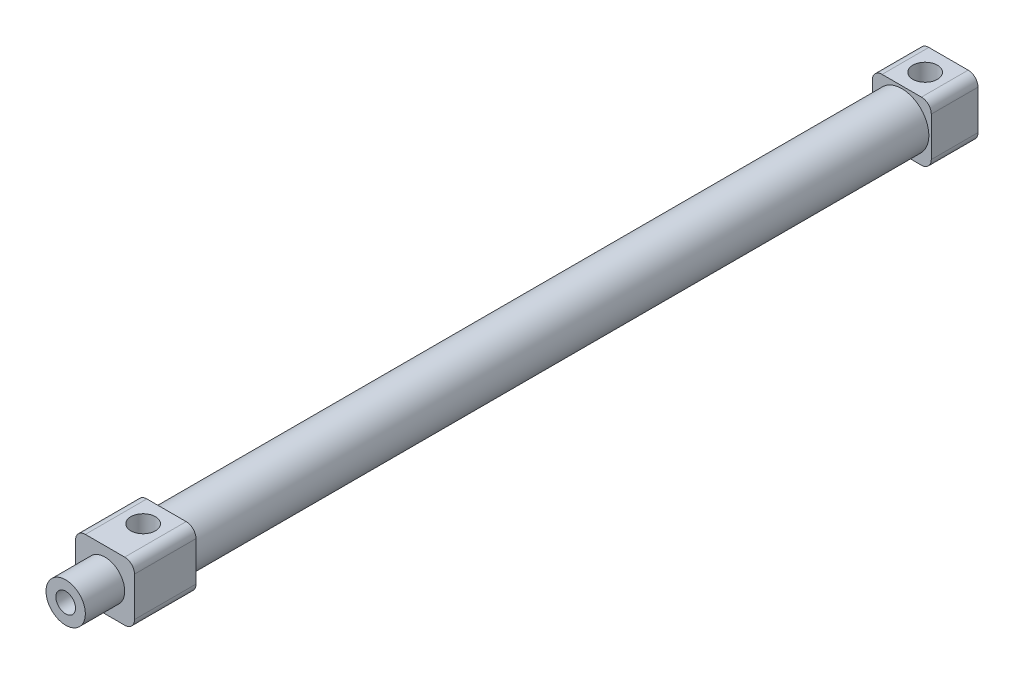
from build123d import *

# Parameters (mm, degrees)
SKETCH_1_W          = 12
SKETCH_1_H          = 12
EXTRUDE_1_DEPTH     = 9.5
SKETCH_2_R          = 5.5
EXTRUDE_2_DEPTH     = 149.5
SKETCH_3_W          = 12
SKETCH_3_H          = 12
EXTRUDE_3_DEPTH     = 12.5
SKETCH_4_R          = 4
EXTRUDE_4_DEPTH     = 8
SKETCH_5_R          = 2
CUT_EXTRUDE_1_DEPTH = 178.5
CUT_EXTRUDE_START   = -6
SKETCH_6_R          = 2.5
CUT_EXTRUDE_2_DEPTH = 6
FILLET_1_R          = 2


with BuildPart() as part:
    # 草图1 → 凸台-拉伸1 (new body)
    with BuildSketch(Plane.XY):
        Rectangle(SKETCH_1_W, SKETCH_1_H)
    extrude(amount=EXTRUDE_1_DEPTH)

    # 草图2 → 凸台-拉伸2 (add)
    with BuildSketch(Plane.XY.offset(9.5)):
        Circle(SKETCH_2_R)
    extrude(amount=EXTRUDE_2_DEPTH)

    # 草图3 → 凸台-拉伸3 (add)
    with BuildSketch(Plane.XY.offset(159)):
        Rectangle(SKETCH_3_W, SKETCH_3_H)
    extrude(amount=EXTRUDE_3_DEPTH)

    # 草图4 → 凸台-拉伸4 (add)
    with BuildSketch(Plane.XY.offset(171.5)):
        Circle(SKETCH_4_R)
    extrude(amount=EXTRUDE_4_DEPTH)

    # 草图5 → 切除-拉伸1 (cut)
    with BuildSketch(Plane.XY.offset(179.5)):
        Circle(SKETCH_5_R)
    extrude(amount=-CUT_EXTRUDE_1_DEPTH, mode=Mode.SUBTRACT)

    # 草图6 → 切除-拉伸2 (cut)
    with BuildSketch(Plane(origin=(0, 6, 0), x_dir=(1, 0, 0), z_dir=(0, 1, 0)).offset(CUT_EXTRUDE_START)):
        with Locations((0, -4.75)):
            Circle(SKETCH_6_R)
        with Locations((0, -163.75)):
            Circle(SKETCH_6_R)
    extrude(amount=CUT_EXTRUDE_2_DEPTH, mode=Mode.SUBTRACT)

    # 圆角1
    fillet_1_edges = [part.edges().sort_by_distance(p)[0] for p in [
        (6, -6, 165.25),
        (6, 6, 165.25),
        (-6, 6, 165.25),
        (-6, -6, 165.25),
        (6, -6, 4.75),
        (-6, -6, 4.75),
        (-6, 6, 4.75),
        (6, 6, 4.75),
    ]]
    fillet(fillet_1_edges, radius=FILLET_1_R)


solid = part.part
